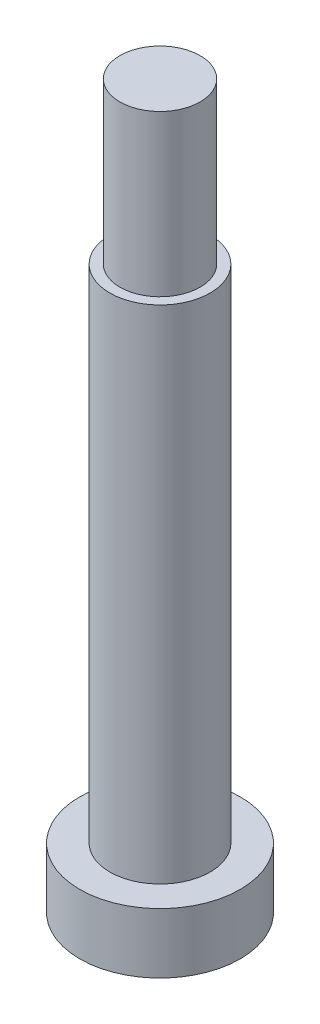
from build123d import *

# Parameters (mm, degrees)
SKETCH_1_R      = 2.5
EXTRUDE_1_DEPTH = 25
SKETCH_2_R      = 2
EXTRUDE_2_DEPTH = 8
SKETCH_3_R      = 4
EXTRUDE_3_DEPTH = 3


with BuildPart() as part:
    # 草图1 → 凸台-拉伸1 (new body)
    with BuildSketch(Plane(origin=(0, 0, 0), x_dir=(1, 0, 0), z_dir=(0, 1, 0))):
        Circle(SKETCH_1_R)
    extrude(amount=EXTRUDE_1_DEPTH)

    # 草图2 → 凸台-拉伸2 (add)
    with BuildSketch(Plane(origin=(0, 25, 0), x_dir=(1, 0, 0), z_dir=(0, 1, 0))):
        Circle(SKETCH_2_R)
    extrude(amount=EXTRUDE_2_DEPTH)

    # 草图3 → 凸台-拉伸3 (add)
    with BuildSketch(Plane.XZ):
        Circle(SKETCH_3_R)
    extrude(amount=EXTRUDE_3_DEPTH)


solid = part.part
